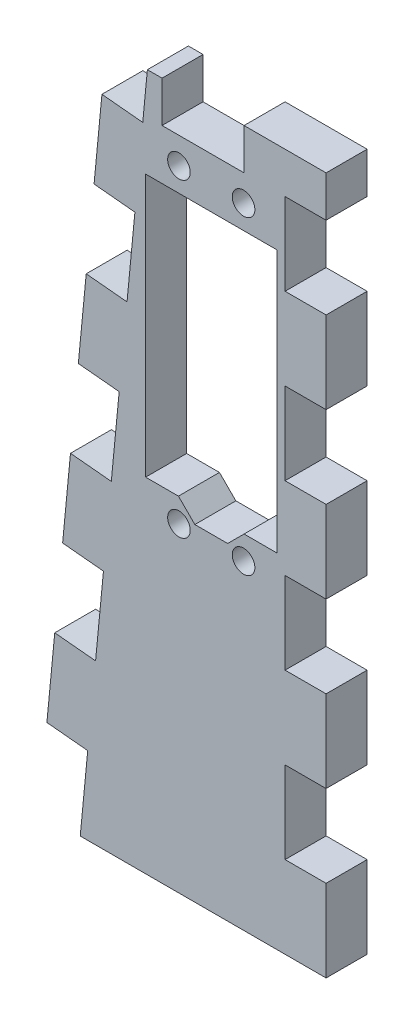
from build123d import *

# Parameters (mm, degrees)
BOSS_EXTRUDE1_DEPTH = 6.35
SKETCH4_R           = 1.75
CUT_EXTRUDE1_DEPTH  = 7.35
SKETCH6_W           = 6.35
SKETCH6_H           = 12.7
CUT_EXTRUDE2_DEPTH  = 7.35
LPATTERN1_COUNT     = 5
LPATTERN1_PITCH     = 25.4
SKETCH7_W           = 12.7
SKETCH7_H           = 6.35
CUT_EXTRUDE3_DEPTH  = 7.35
CUT_EXTRUDE4_DEPTH  = 7.35
LPATTERN2_COUNT     = 5
LPATTERN2_PITCH     = 25.4


with BuildPart() as part:
    # Sketch2 → Boss-Extrude1 (new body)
    with BuildSketch(Plane.XY):
        Polygon((19.565934594, 203.2), (29.960337347, 311.15), (64.008541785, 311.15), (64.008541785, 203.2), align=None)
    extrude(amount=BOSS_EXTRUDE1_DEPTH)

    # Sketch4 → Cut-Extrude1 (cut, through all)
    with BuildSketch(Plane.XY.offset(6.35)):
        with Locations((41.228541785, 300.7)):
            Circle(SKETCH4_R)
        with Locations((51.228541785, 300.7)):
            Circle(SKETCH4_R)
        with Locations((41.228541785, 252.7)):
            Circle(SKETCH4_R)
        with Locations((51.228541785, 252.7)):
            Circle(SKETCH4_R)
        Polygon((56.388541785, 256.38), (56.388541785, 297.02), (36.068541785, 297.02), (36.068541785, 256.38), (41.148541785, 256.38), (43.688541785, 253.84), (48.768541785, 253.84), (51.308541785, 256.38), align=None)
    extrude(amount=-CUT_EXTRUDE1_DEPTH, mode=Mode.SUBTRACT)

    # Sketch6 → Cut-Extrude2 (cut, through all)
    with BuildSketch(Plane.XY.offset(6.35)):
        with Locations((60.833541785, 298.45)):
            Rectangle(SKETCH6_W, SKETCH6_H)
    cut_extrude2 = extrude(amount=-CUT_EXTRUDE2_DEPTH, mode=Mode.SUBTRACT)

    # LPattern1: Cut-Extrude2 ×5
    with Locations(*[(0, -i * LPATTERN1_PITCH, 0) for i in range(1, LPATTERN1_COUNT)]):
        add(cut_extrude2, mode=Mode.SUBTRACT)

    # Sketch7 → Cut-Extrude3 (cut, through all)
    with BuildSketch(Plane.XY.offset(6.35)):
        with Locations((44.958541785, 307.975)):
            Rectangle(SKETCH7_W, SKETCH7_H)
    extrude(amount=-CUT_EXTRUDE3_DEPTH, mode=Mode.SUBTRACT)

    # Sketch8 → Cut-Extrude4 (cut, through all)
    with BuildSketch(Plane.XY.offset(6.35)):
        Polygon((19.565934594, 203.2), (20.783175651, 215.841531719), (27.10394151, 215.232911191), (25.886700453, 202.591379471), align=None)
    cut_extrude4 = extrude(amount=-CUT_EXTRUDE4_DEPTH, mode=Mode.SUBTRACT)

    # LPattern2: Cut-Extrude4 ×5
    with Locations(*[Vector(0.095845753, 0.995396198, 0) * (i * LPATTERN2_PITCH) for i in range(1, LPATTERN2_COUNT)]):
        add(cut_extrude4, mode=Mode.SUBTRACT)


solid = part.part
